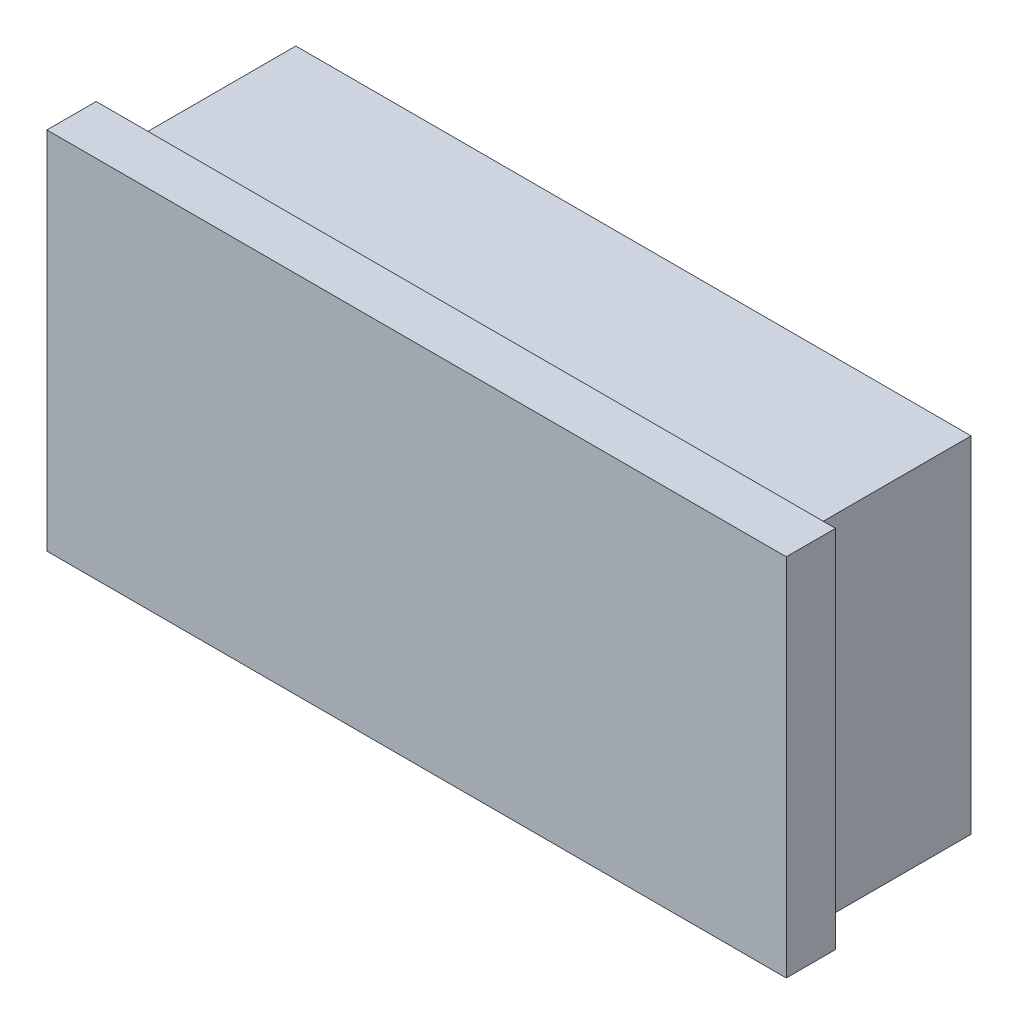
from build123d import *

# Parameters (mm, degrees)
ESBO_O1_W                = 548
ESBO_O1_H                = 280
RESSALTO_EXTRUS_O1_DEPTH = 176
ESBO_O2_W                = 40
ESBO_O2_H                = 280
RESSALTO_EXTRUS_O2_DEPTH = 26
ESBO_O3_W                = 40
ESBO_O3_H                = 280
RESSALTO_EXTRUS_O3_DEPTH = 26
ESBO_O4_W                = 600
ESBO_O4_H                = 40
RESSALTO_EXTRUS_O4_DEPTH = 16


with BuildPart() as part:
    # Esboço1 → Ressalto-extrusão1 (new body)
    with BuildSketch(Plane.XY):
        with Locations((274, 140)):
            Rectangle(ESBO_O1_W, ESBO_O1_H)
    extrude(amount=RESSALTO_EXTRUS_O1_DEPTH)

    # Esboço2 → Ressalto-extrusão2 (add)
    with BuildSketch(Plane.ZY):
        with Locations((156, 140)):
            Rectangle(ESBO_O2_W, ESBO_O2_H)
    extrude(amount=RESSALTO_EXTRUS_O2_DEPTH)

    # Esboço3 → Ressalto-extrusão3 (add)
    with BuildSketch(Plane(origin=(548, 0, 0), x_dir=(0, 0, -1), z_dir=(1, 0, 0))):
        with Locations((-156, 140)):
            Rectangle(ESBO_O3_W, ESBO_O3_H)
    extrude(amount=RESSALTO_EXTRUS_O3_DEPTH)

    # Esboço4 → Ressalto-extrusão4 (add)
    with BuildSketch(Plane(origin=(0, 280, 0), x_dir=(1, 0, 0), z_dir=(0, 1, 0))):
        with Locations((274, -156)):
            Rectangle(ESBO_O4_W, ESBO_O4_H)
    extrude(amount=RESSALTO_EXTRUS_O4_DEPTH)


solid = part.part
